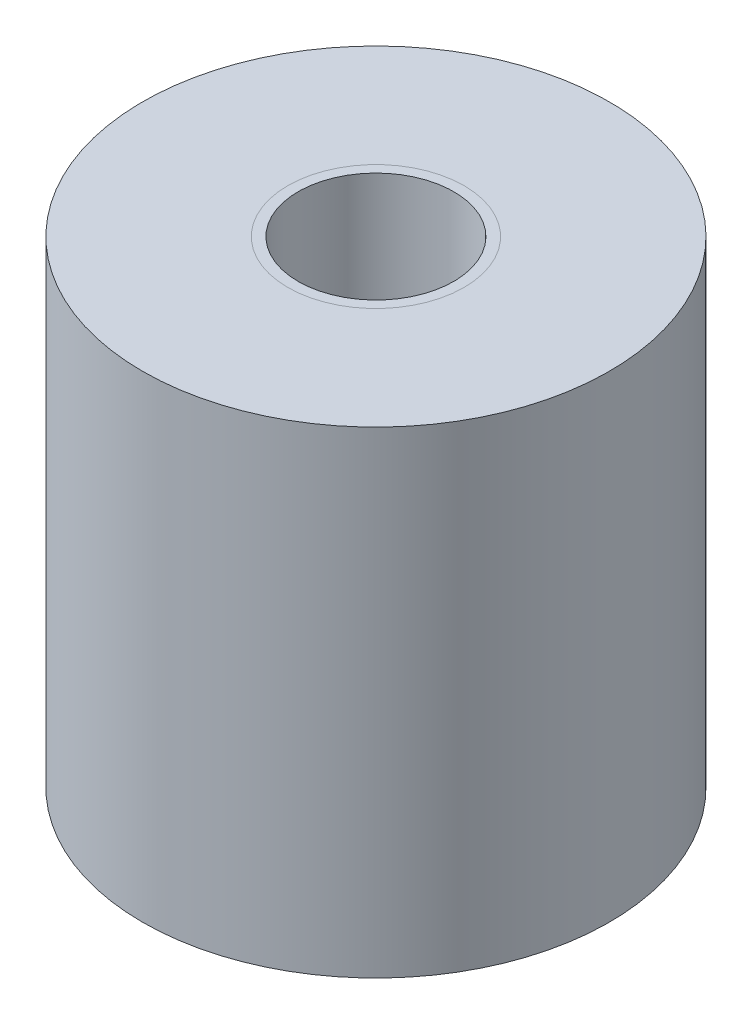
from build123d import *

# Parameters (mm, degrees)
SKETCH1_R           = 57.15
SKETCH1_R_2         = 19.05
BOSS_EXTRUDE1_DEPTH = 116.84


with BuildPart() as part:
    # Sketch1 → Boss-Extrude1 (new body)
    with BuildSketch(Plane(origin=(0, 0, 0), x_dir=(1, 0, 0), z_dir=(0, 1, 0))):
        Circle(SKETCH1_R)
        Circle(SKETCH1_R_2, mode=Mode.SUBTRACT)
    extrude(amount=BOSS_EXTRUDE1_DEPTH)


solid = part.part
